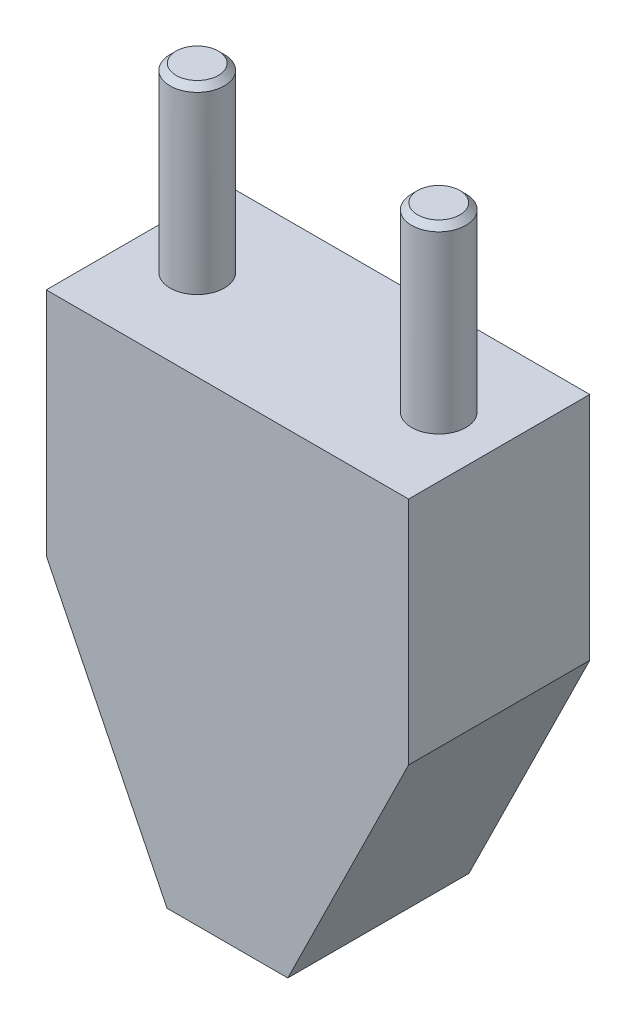
from build123d import *

# Parameters (mm, degrees)
BOSS_EXTRUDE1_DEPTH = 15
SKETCH2_R           = 2.25
BOSS_EXTRUDE2_DEPTH = 15
CHAMFER4_SIZE       = 0.5
CHAMFER5_SIZE       = 0.5
SKETCH4_R           = 3
CUT_EXTRUDE1_DEPTH  = 5


with BuildPart() as part:
    # Sketch1 → Boss-Extrude1 (new body)
    with BuildSketch(Plane.XY):
        Polygon((-21.283297093, 0), (8.716702907, 0), (8.716702907, -19.069471621), (-1.283297093, -39.344386688), (-11.283297093, -39.344386688), (-21.283297093, -19.069471621), align=None)
    extrude(amount=BOSS_EXTRUDE1_DEPTH)

    # Sketch2 → Boss-Extrude2 (add)
    with BuildSketch(Plane(origin=(0, 0, 0), x_dir=(1, 0, 0), z_dir=(0, 1, 0))):
        with Locations((-16.283297093, -7.5)):
            Circle(SKETCH2_R)
        with Locations((3.716702907, -7.5)):
            Circle(SKETCH2_R)
    extrude(amount=BOSS_EXTRUDE2_DEPTH)

    # Chamfer4
    chamfer4_edges = [part.edges().sort_by_distance(p)[0] for p in [
        (-18.533297093, 15, 7.5),
    ]]
    chamfer(chamfer4_edges, length=CHAMFER4_SIZE)

    # Chamfer5
    chamfer5_edges = [part.edges().sort_by_distance(p)[0] for p in [
        (1.466702907, 15, 7.5),
    ]]
    chamfer(chamfer5_edges, length=CHAMFER5_SIZE)

    # Sketch4 → Cut-Extrude1 (cut)
    with BuildSketch(Plane(origin=(0, -39.344386688, 0), x_dir=(-1, 0, 0), z_dir=(0, -1, 0))):
        with Locations((6.283297093, -7.5)):
            Circle(SKETCH4_R)
    extrude(amount=-CUT_EXTRUDE1_DEPTH, mode=Mode.SUBTRACT)


solid = part.part
